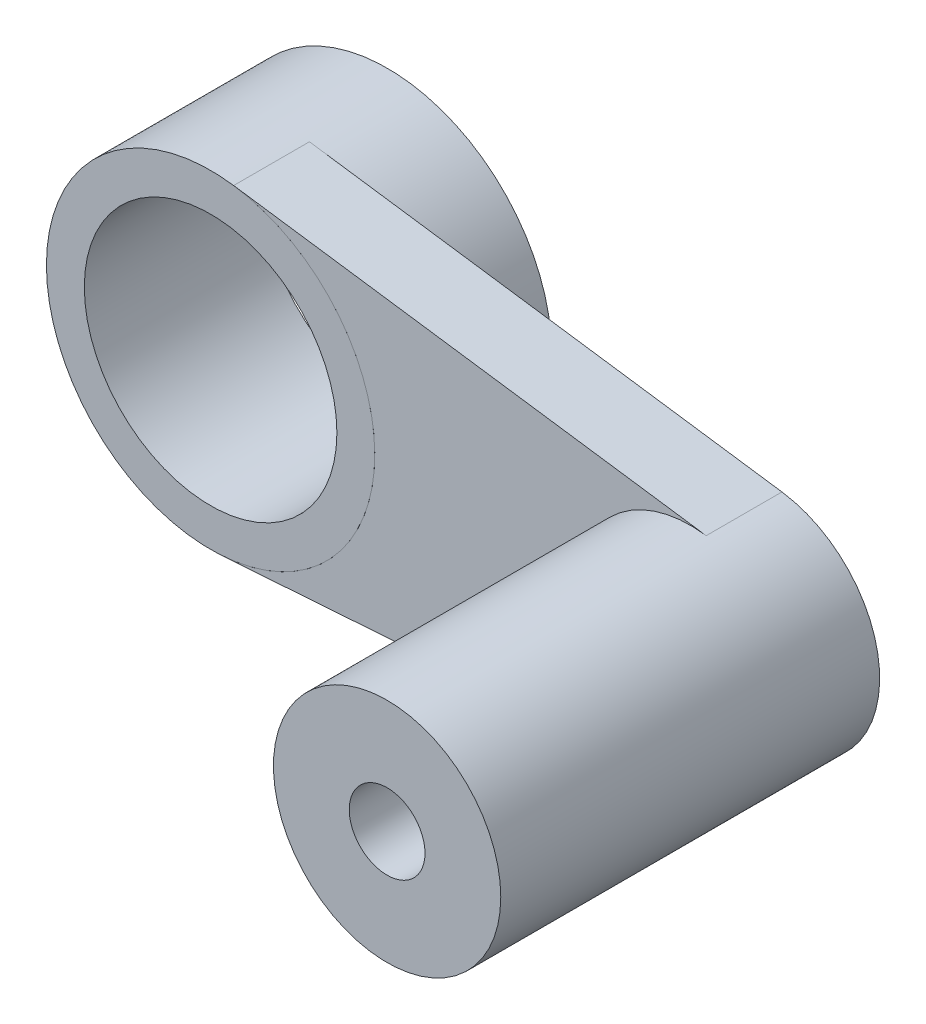
from build123d import *

# Parameters (mm, degrees)
CROQUIS1_R              = 3
SALIENTE_EXTRUIR1_DEPTH = 24
CROQUIS1_4_R            = 10
SALIENTE_EXTRUIR2_DEPTH = 14
SALIENTE_EXTRUIR5_START = -6
CROQUIS1_11_R           = 3
SALIENTE_EXTRUIR5_DEPTH = 6


with BuildPart() as part:
    # Croquis1 → Saliente-Extruir1 (new body)
    with BuildSketch(Plane.XY):
        with BuildLine():
            ThreePointArc((47.531883149, 15.493750807), (45.327935293, 21.394062261), (39.79551087, 24.404600653))
            ThreePointArc((39.79551087, 24.404600653), (29.537524962, 15.812374125), (39.161804519, 6.515822367))
            ThreePointArc((39.161804519, 6.515822367), (45.114788751, 9.356540216), (47.531883149, 15.493750807))
        make_face()
        with Locations((38.531883149, 15.493750807)):
            Circle(CROQUIS1_R, mode=Mode.SUBTRACT)
    extrude(amount=SALIENTE_EXTRUIR1_DEPTH)

    # Croquis1_11 → Saliente-Extruir5 (add)
    with BuildSketch(Plane.XY.offset(SALIENTE_EXTRUIR5_START)):
        with BuildLine():
            Line((39.79551087, 24.404600653), (2.380944182, 29.710276818))
            ThreePointArc((2.380944182, 29.710276818), (13.547554854, 16.37881558), (1.465590565, 3.870930405))
            Line((1.465590565, 3.870930405), (39.161804519, 6.515822367))
            ThreePointArc((39.161804519, 6.515822367), (47.526241335, 15.175127489), (39.79551087, 24.404600653))
        make_face()
        with Locations((38.531883149, 15.493750807)):
            Circle(CROQUIS1_11_R, mode=Mode.SUBTRACT)
    extrude(amount=SALIENTE_EXTRUIR5_DEPTH)


with BuildPart() as body_2:
    # Croquis1_4 → Saliente-Extruir2 (new body)
    with BuildSketch(Plane.XY):
        with BuildLine():
            ThreePointArc((13.55570414, 16.839049262), (10.372223904, 25.361721363), (2.380944182, 29.710276818))
            ThreePointArc((2.380944182, 29.710276818), (-12.436146573, 17.299282944), (1.465590565, 3.870930405))
            ThreePointArc((1.465590565, 3.870930405), (10.064345566, 7.974189521), (13.55570414, 16.839049262))
        make_face()
        with Locations((0.55570414, 16.839049262)):
            Circle(CROQUIS1_4_R, mode=Mode.SUBTRACT)
    extrude(amount=-SALIENTE_EXTRUIR2_DEPTH)


solid = Compound([part.part, body_2.part])
